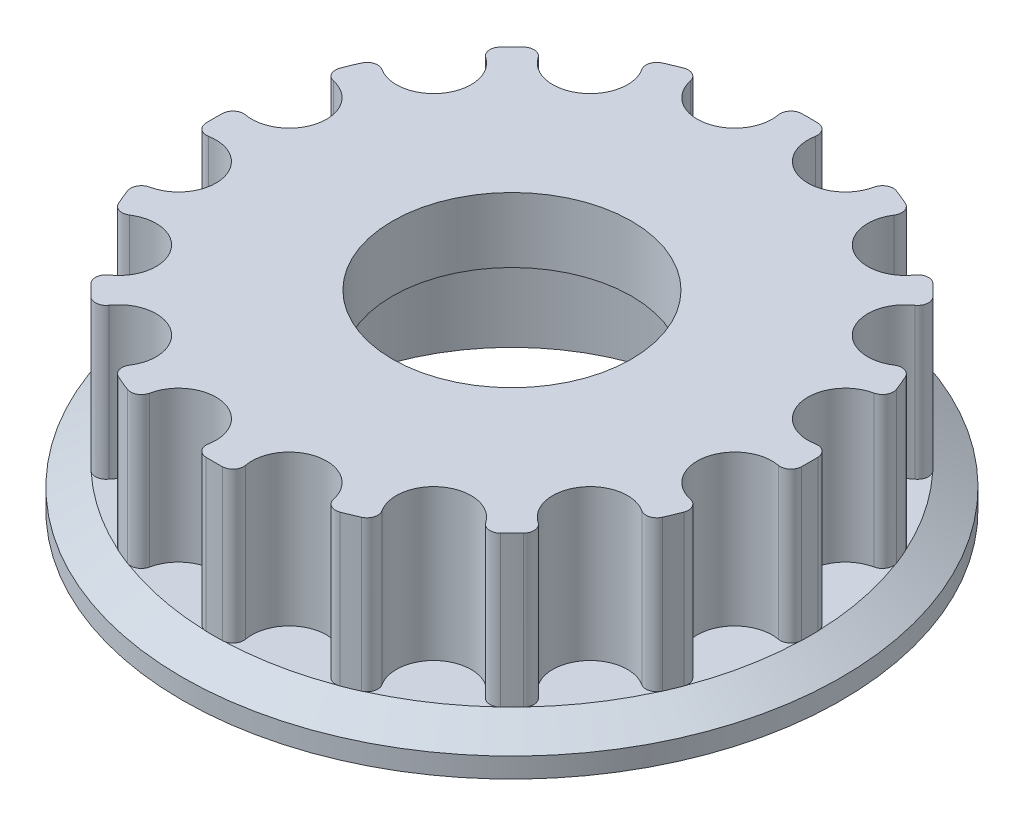
from build123d import *

# Parameters (mm, degrees)
SKETCH1_R           = 12.732395445
BOSS_EXTRUDE1_DEPTH = 6
CUT_EXTRUDE1_DEPTH  = 6
CIRPATTERN1_COUNT   = 16
SKETCH4_R           = 7.9375
SKETCH4_R_2         = 4.7625
CUT_EXTRUDE4_DEPTH  = 5
SKETCH4_5_R         = 4.7625
CUT_EXTRUDE5_DEPTH  = 8.5875


with BuildPart() as part:
    # Sketch1 → Boss-Extrude1 (new body)
    with BuildSketch(Plane(origin=(0, 0, 0), x_dir=(1, 0, 0), z_dir=(0, 1, 0))):
        Circle(SKETCH1_R)
    extrude(amount=BOSS_EXTRUDE1_DEPTH)

    # Sketch3 → Cut-Extrude1 (cut)
    with BuildSketch(Plane(origin=(0, 0, 0), x_dir=(1, 0, 0), z_dir=(0, 1, 0))):
        with BuildLine():
            Line((5.255160224, 12.687079084), (4.539542206, 10.959424358))
            ThreePointArc((4.539542206, 10.959424358), (4.387777638, 11.021063156), (4.235176409, 11.080600457))
            ThreePointArc((4.235176409, 11.080600457), (3.875932689, 11.056534938), (3.660923238, 10.767733734))
            ThreePointArc((3.660923238, 10.767733734), (1.912352484, 9.614045165), (0.738381256, 11.349063479))
            ThreePointArc((0.738381256, 11.349063479), (0.65025786, 11.698161555), (0.327569416, 11.857871815))
            ThreePointArc((0.327569416, 11.857871815), (0.163800325, 11.861264483), (0, 11.862395445))
            Line((0, 11.862395445), (0, 13.732395445))
            ThreePointArc((0, 13.732395445), (2.67905745, 13.468531317), (5.255160224, 12.687079084))
        make_face()
    cut_extrude1 = extrude(amount=CUT_EXTRUDE1_DEPTH, mode=Mode.SUBTRACT)

    # CirPattern1: Cut-Extrude1 ×16 about axis
    cirpattern1_axis = Axis((0, 0, 0), (0, 1, 0))
    for i in range(1, CIRPATTERN1_COUNT):
        add(cut_extrude1.rotate(cirpattern1_axis, i * 360 / CIRPATTERN1_COUNT), mode=Mode.SUBTRACT)

    # Sketch5 → Revolve1 (revolve)
    with BuildSketch(Plane.XY):
        Polygon((0, 0), (0, -1.5875), (-13.127871815, -1.5875), (-13.127871815, -0.79375), (-11.857871815, 0), align=None)
    revolve(axis=Axis((0, 0, 0), (0, -1, 0)))

    # Sketch4 → Cut-Extrude4 (cut)
    with BuildSketch(Plane.XZ.offset(1.5875)):
        Circle(SKETCH4_R)
        Circle(SKETCH4_R_2, mode=Mode.SUBTRACT)
    extrude(amount=-CUT_EXTRUDE4_DEPTH, mode=Mode.SUBTRACT)

    # Sketch4_5 → Cut-Extrude5 (cut, through all)
    with BuildSketch(Plane.XZ.offset(1.5875)):
        Circle(SKETCH4_5_R)
    extrude(amount=-CUT_EXTRUDE5_DEPTH, mode=Mode.SUBTRACT)


solid = part.part
